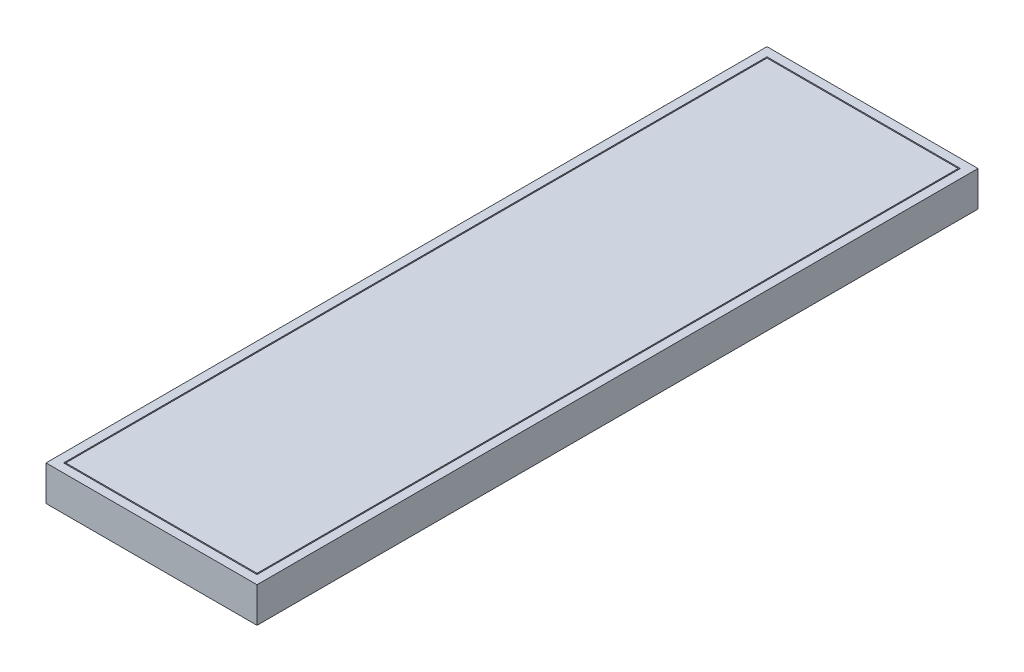
from build123d import *

# Parameters (mm, degrees)
SKETCH1_W           = 480
SKETCH1_H           = 1640
BOSS_EXTRUDE1_DEPTH = 80
SKETCH2_W           = 440
SKETCH2_H           = 1600
CUT_EXTRUDE1_DEPTH  = 11
SKETCH3_W           = 435
SKETCH3_H           = 1595
BOSS_EXTRUDE2_DEPTH = 11


with BuildPart() as part:
    # Sketch1 → Boss-Extrude1 (new body)
    with BuildSketch(Plane.XZ.offset(60)):
        with Locations((0, 820)):
            Rectangle(SKETCH1_W, SKETCH1_H)
    extrude(amount=-BOSS_EXTRUDE1_DEPTH)

    # Sketch2 → Cut-Extrude1 (cut)
    with BuildSketch(Plane(origin=(0, 20, 0), x_dir=(-1, 0, 0), z_dir=(0, 1, 0))):
        with Locations((0, 820)):
            Rectangle(SKETCH2_W, SKETCH2_H)
    extrude(amount=-CUT_EXTRUDE1_DEPTH, mode=Mode.SUBTRACT)

    # Sketch3 → Boss-Extrude2 (add)
    with BuildSketch(Plane(origin=(0, 9, 0), x_dir=(-1, 0, 0), z_dir=(0, 1, 0))):
        with Locations((0, 820)):
            Rectangle(SKETCH3_W, SKETCH3_H)
    extrude(amount=BOSS_EXTRUDE2_DEPTH)


solid = part.part
